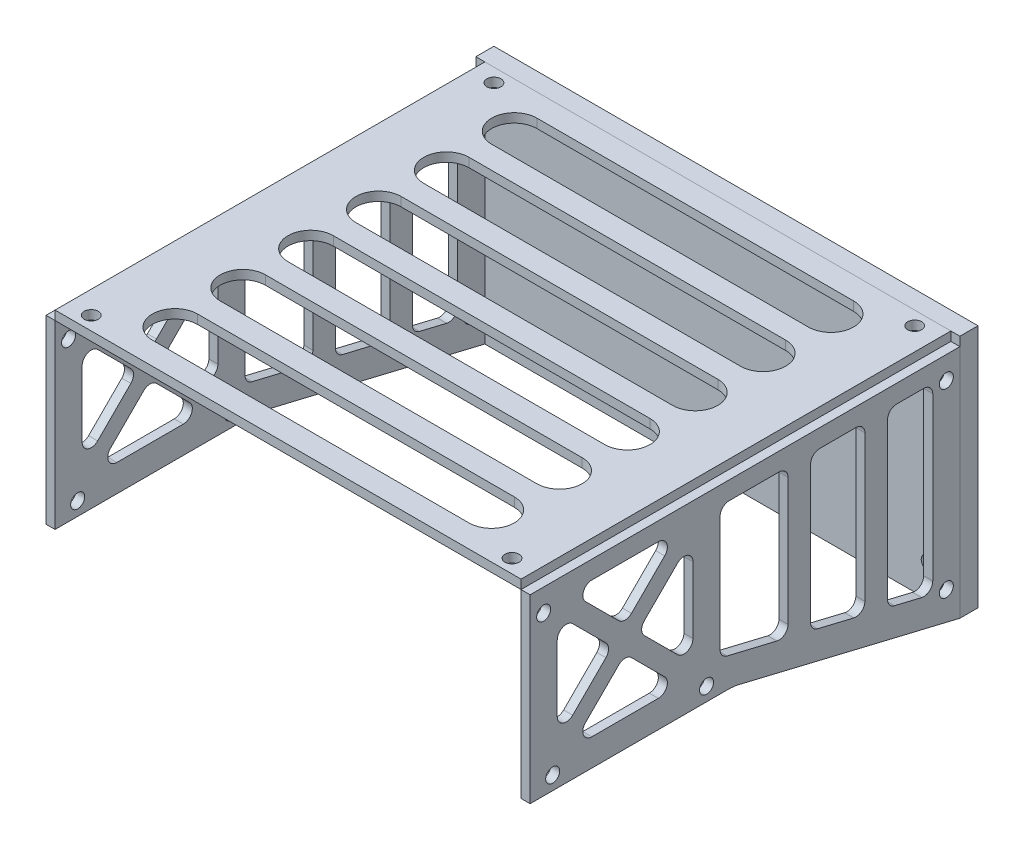
from build123d import *

# Parameters (mm, degrees)
SKETCH_1_W          = 103
SKETCH_1_H          = 95
SKETCH_1_R          = 1.55
EXTRUDE_1_DEPTH     = 2
EXTRUDE_START       = -51.5
SKETCH_2_R          = 1.55
EXTRUDE_2_DEPTH     = 2
EXTRUDE_START_2     = 51.5
SKETCH_2_2_R        = 1.55
EXTRUDE_3_DEPTH     = 2
SKETCH_3_W          = 107
SKETCH_3_H          = 54
SKETCH_3_R          = 1.55
EXTRUDE_4_DEPTH     = 4
CUT_EXTRUDE_1_DEPTH = 55
CUT_EXTRUDE_3_DEPTH = 108
FILLET_3_R          = 2
FILLET_4_R          = 2


with BuildPart() as part:
    # 草图1 → 凸台-拉伸1 (new body)
    with BuildSketch(Plane(origin=(0, 0, 0), x_dir=(1, 0, 0), z_dir=(0, 1, 0))):
        Rectangle(SKETCH_1_W, SKETCH_1_H)
        with Locations((46.5, -44.5)):
            Circle(SKETCH_1_R, mode=Mode.SUBTRACT)
        with Locations((-46.5, -44.5)):
            Circle(SKETCH_1_R, mode=Mode.SUBTRACT)
        with Locations((-46.5, 44.5)):
            Circle(SKETCH_1_R, mode=Mode.SUBTRACT)
        with Locations((46.5, 44.5)):
            Circle(SKETCH_1_R, mode=Mode.SUBTRACT)
    extrude(amount=EXTRUDE_1_DEPTH)

    # 草图5 → 切除-拉伸1 (cut, through all)
    with BuildSketch(Plane(origin=(0, 2, 0), x_dir=(1, 0, 0), z_dir=(0, 1, 0))):
        with BuildLine():
            Line((35, 32.5), (-35, 32.5))
            ThreePointArc((-35, 32.5), (-40, 37.5), (-35, 42.5))
            Line((-35, 42.5), (35, 42.5))
            ThreePointArc((35, 42.5), (40, 37.5), (35, 32.5))
        make_face()
        with BuildLine():
            Line((35, 27.5), (-35, 27.5))
            ThreePointArc((-35, 27.5), (-40, 22.5), (-35, 17.5))
            Line((-35, 17.5), (35, 17.5))
            ThreePointArc((35, 17.5), (40, 22.5), (35, 27.5))
        make_face()
        with BuildLine():
            Line((35, 12.5), (-35, 12.5))
            ThreePointArc((-35, 12.5), (-40, 7.5), (-35, 2.5))
            Line((-35, 2.5), (35, 2.5))
            ThreePointArc((35, 2.5), (40, 7.5), (35, 12.5))
        make_face()
        with BuildLine():
            Line((35, -2.5), (-35, -2.5))
            ThreePointArc((-35, -2.5), (-40, -7.5), (-35, -12.5))
            Line((-35, -12.5), (35, -12.5))
            ThreePointArc((35, -12.5), (40, -7.5), (35, -2.5))
        make_face()
        with BuildLine():
            Line((35, -17.5), (-35, -17.5))
            ThreePointArc((-35, -17.5), (-40, -22.5), (-35, -27.5))
            Line((-35, -27.5), (35, -27.5))
            ThreePointArc((35, -27.5), (40, -22.5), (35, -17.5))
        make_face()
        with BuildLine():
            Line((35, -32.5), (-35, -32.5))
            ThreePointArc((-35, -32.5), (-40, -37.5), (-35, -42.5))
            Line((-35, -42.5), (35, -42.5))
            ThreePointArc((35, -42.5), (40, -37.5), (35, -32.5))
        make_face()
    extrude(amount=-CUT_EXTRUDE_1_DEPTH, mode=Mode.SUBTRACT)


with BuildPart() as body_2:
    # 草图2 → 凸台-拉伸2 (new body)
    with BuildSketch(Plane(origin=(0, 0, 0), x_dir=(0, 0, -1), z_dir=(1, 0, 0)).offset(EXTRUDE_START)):
        with BuildLine():
            Line((-47.5, -40), (-3.683200441, -40))
            ThreePointArc((-3.683200441, -40), (-2.508196227, -40.069271673), (-1.349470916, -40.27612698))
            Line((-1.349470916, -40.27612698), (47.5, -52))
            Line((47.5, -52), (47.5, -40))
            Line((47.5, -40), (47.5, 0))
            Line((47.5, 0), (-47.5, 0))
            Line((-47.5, 0), (-47.5, -40))
        make_face()
        with Locations((-8.5, -37)):
            Circle(SKETCH_2_R, mode=Mode.SUBTRACT)
        with Locations((-42.5, -37)):
            Circle(SKETCH_2_R, mode=Mode.SUBTRACT)
        with Locations((-44.5, -5)):
            Circle(SKETCH_2_R, mode=Mode.SUBTRACT)
        with Locations((44.5, -5)):
            Circle(SKETCH_2_R, mode=Mode.SUBTRACT)
        with Locations((44.5, -45)):
            Circle(SKETCH_2_R, mode=Mode.SUBTRACT)
    extrude(amount=-EXTRUDE_2_DEPTH)


with BuildPart() as body_3:
    # 草图2<2> → 凸台-拉伸3 (new body)
    with BuildSketch(Plane(origin=(0, 0, 0), x_dir=(0, 0, -1), z_dir=(1, 0, 0)).offset(EXTRUDE_START_2)):
        with BuildLine():
            Line((-47.5, -40), (-3.683200441, -40))
            ThreePointArc((-3.683200441, -40), (-2.508196227, -40.069271673), (-1.349470916, -40.27612698))
            Line((-1.349470916, -40.27612698), (47.5, -52))
            Line((47.5, -52), (47.5, -40))
            Line((47.5, -40), (47.5, 0))
            Line((47.5, 0), (-47.5, 0))
            Line((-47.5, 0), (-47.5, -40))
        make_face()
        with Locations((-8.5, -37)):
            Circle(SKETCH_2_2_R, mode=Mode.SUBTRACT)
        with Locations((-42.5, -37)):
            Circle(SKETCH_2_2_R, mode=Mode.SUBTRACT)
        with Locations((-44.5, -5)):
            Circle(SKETCH_2_2_R, mode=Mode.SUBTRACT)
        with Locations((44.5, -5)):
            Circle(SKETCH_2_2_R, mode=Mode.SUBTRACT)
        with Locations((44.5, -45)):
            Circle(SKETCH_2_2_R, mode=Mode.SUBTRACT)
    extrude(amount=EXTRUDE_3_DEPTH)


with BuildPart() as body_4:
    # 草图3 → 凸台-拉伸4 (new body)
    with BuildSketch(Plane(origin=(0, 0, -47.5), x_dir=(-1, 0, 0), z_dir=(0, 0, -1))):
        with Locations((0, -25)):
            Rectangle(SKETCH_3_W, SKETCH_3_H)
        with Locations((46.5, -5)):
            Circle(SKETCH_3_R, mode=Mode.SUBTRACT)
        with Locations((-46.5, -5)):
            Circle(SKETCH_3_R, mode=Mode.SUBTRACT)
        with Locations((-46.5, -45)):
            Circle(SKETCH_3_R, mode=Mode.SUBTRACT)
        with Locations((46.5, -45)):
            Circle(SKETCH_3_R, mode=Mode.SUBTRACT)
    extrude(amount=EXTRUDE_4_DEPTH)


with BuildPart() as cut_extrude_3_tool:
    # 草图8 → 切除-拉伸3 (new body, through all)
    with BuildSketch(Plane.ZY.offset(53.5)):
        Polygon((-31.5, -4), (-41.5, -4), (-41.5, -44.389619137), (-31.5, -41.989619137), align=None)
        Polygon((-14.5, -4), (-26.5, -4), (-26.5, -40.789619137), (-14.5, -37.909619137), align=None)
        Polygon((5.5, -4), (-9.5, -4), (-9.5, -36.709619137), (5.5, -33.109619137), align=None)
        Polygon((23.671572875, -19), (11.5, -6.828427125), (11.5, -31.171572875), align=None)
        Polygon((38.671572875, -4), (14.328427125, -4), (26.5, -16.171572875), align=None)
        Polygon((41.5, -31.171572875), (41.5, -6.828427125), (29.328427125, -19), align=None)
        Polygon((26.5, -21.828427125), (14.328427125, -34), (38.671572875, -34), align=None)
    extrude(amount=-CUT_EXTRUDE_3_DEPTH)


with BuildPart() as body_2_1:
    add(body_2.part)

    # 切除-拉伸3: cut by cut_extrude_3_tool
    add(cut_extrude_3_tool.part, mode=Mode.SUBTRACT)

    # 圆角3
    fillet_3_edges = [body_2_1.edges().sort_by_distance(p)[0] for p in [
        (-52.5, -19, 23.671572875),
        (-52.5, -31.171572875, 11.5),
        (-52.5, -4, 14.328427125),
        (-52.5, -4, 38.671572875),
        (-52.5, -16.171572875, 26.5),
        (-52.5, -19, 29.328427125),
        (-52.5, -6.828427125, 41.5),
        (-52.5, -31.171572875, 41.5),
        (-52.5, -21.828427125, 26.5),
        (-52.5, -34, 38.671572875),
        (-52.5, -34, 14.328427125),
        (-52.5, -4, -31.5),
        (-52.5, -41.989619137, -31.5),
        (-52.5, -44.389619137, -41.5),
        (-52.5, -4, -41.5),
        (-52.5, -4, -14.5),
        (-52.5, -37.909619137, -14.5),
        (-52.5, -40.789619137, -26.5),
        (-52.5, -4, -26.5),
        (-52.5, -4, -9.5),
        (-52.5, -4, 5.5),
        (-52.5, -33.109619137, 5.5),
        (-52.5, -36.709619137, -9.5),
        (-52.5, -6.828427125, 11.5),
    ]]
    fillet(fillet_3_edges, radius=FILLET_3_R)


with BuildPart() as body_3_1:
    add(body_3.part)

    # 切除-拉伸3: cut by cut_extrude_3_tool
    add(cut_extrude_3_tool.part, mode=Mode.SUBTRACT)

    # 圆角4
    fillet_4_edges = [body_3_1.edges().sort_by_distance(p)[0] for p in [
        (52.5, -4, 14.328427125),
        (52.5, -4, 38.671572875),
        (52.5, -16.171572875, 26.5),
        (52.5, -19, 29.328427125),
        (52.5, -6.828427125, 41.5),
        (52.5, -31.171572875, 41.5),
        (52.5, -21.828427125, 26.5),
        (52.5, -34, 38.671572875),
        (52.5, -34, 14.328427125),
        (52.5, -4, -31.5),
        (52.5, -41.989619137, -31.5),
        (52.5, -44.389619137, -41.5),
        (52.5, -4, -41.5),
        (52.5, -4, -14.5),
        (52.5, -37.909619137, -14.5),
        (52.5, -40.789619137, -26.5),
        (52.5, -4, -26.5),
        (52.5, -4, -9.5),
        (52.5, -4, 5.5),
        (52.5, -33.109619137, 5.5),
        (52.5, -36.709619137, -9.5),
        (52.5, -6.828427125, 11.5),
        (52.5, -19, 23.671572875),
        (52.5, -31.171572875, 11.5),
    ]]
    fillet(fillet_4_edges, radius=FILLET_4_R)


solid = Compound([part.part, body_4.part, body_2_1.part, body_3_1.part])
